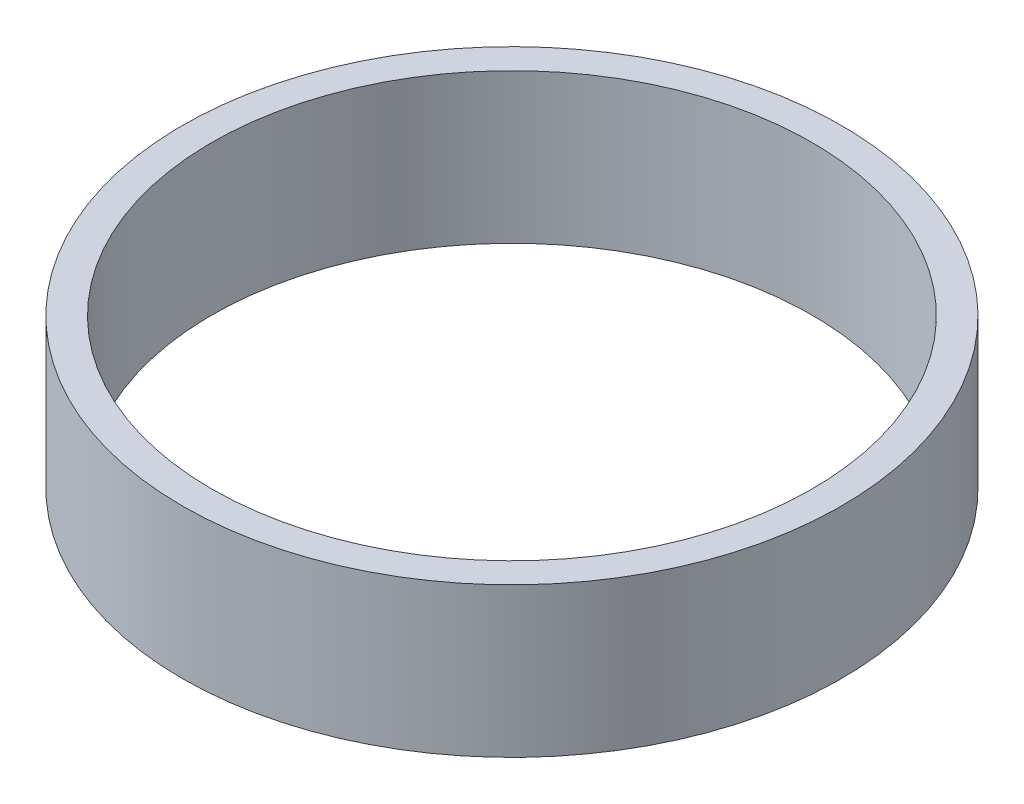
from build123d import *

# Parameters (mm, degrees)
SKETCH_1_W = 2.5
SKETCH_1_H = 12.7


with BuildPart() as part:
    # 草图1 → 旋转1 (revolve)
    with BuildSketch(Plane.XY, mode=Mode.PRIVATE) as revolve_1_sk:
        with Locations((26.75, 6.35)):
            Rectangle(SKETCH_1_W, SKETCH_1_H)
    revolve(revolve_1_sk.sketch.rotate(Axis((0, 161.376166943, 0), (0, -1, 0)), 90), axis=Axis((0, 161.376166943, 0), (0, -1, 0)))  # turned: the seam where the file's is


solid = part.part
